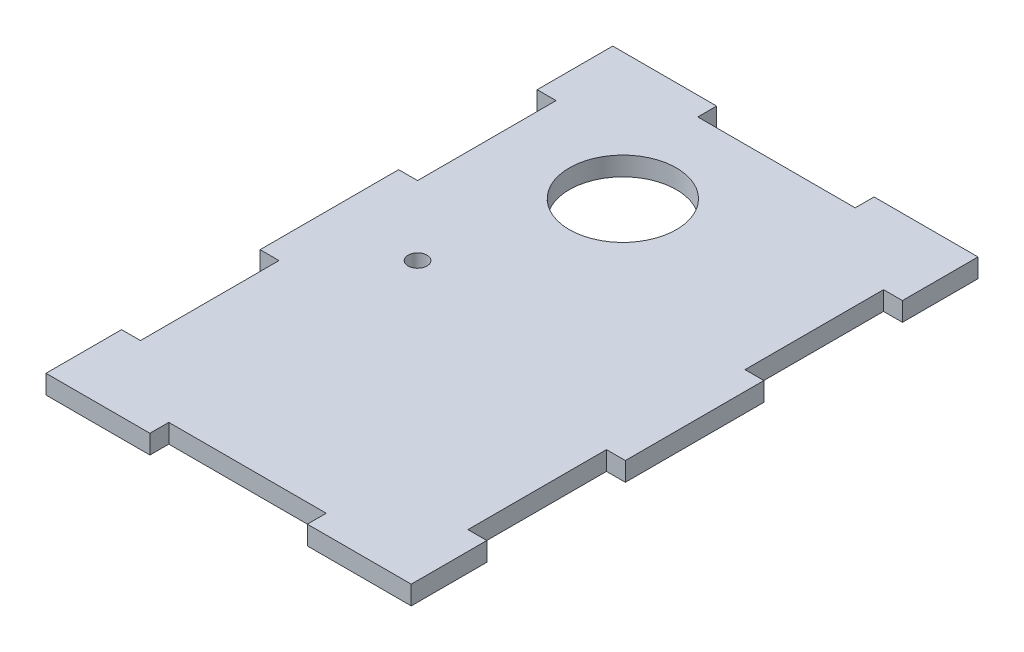
from build123d import *

# Parameters (mm, degrees)
SKETCH4_R           = 8.5
SKETCH4_R_2         = 1.5
BOSS_EXTRUDE1_DEPTH = 3


with BuildPart() as part:
    # Sketch4 → Boss-Extrude1 (new body)
    with BuildSketch(Plane(origin=(0, 0, 0), x_dir=(1, 0, 0), z_dir=(0, 1, 0))):
        Polygon((-26, -90), (-9.5, -90), (-9.5, -87), (15.5, -87), (15.5, -90), (32, -90), (32, -78), (29, -78), (29, -56), (32, -56), (32, -34), (29, -34), (29, -12), (32, -12), (32, 0), (15.5, 0), (15.5, -3), (-9.5, -3), (-9.5, 0), (-26, 0), (-26, -12), (-23, -12), (-23, -34), (-26, -34), (-26, -56), (-23, -56), (-23, -78), (-26, -78), align=None)
        with Locations((-4.2, -20.197580763)):
            Circle(SKETCH4_R, mode=Mode.SUBTRACT)
        with Locations((-12, -45)):
            Circle(SKETCH4_R_2, mode=Mode.SUBTRACT)
    extrude(amount=BOSS_EXTRUDE1_DEPTH)


solid = part.part
